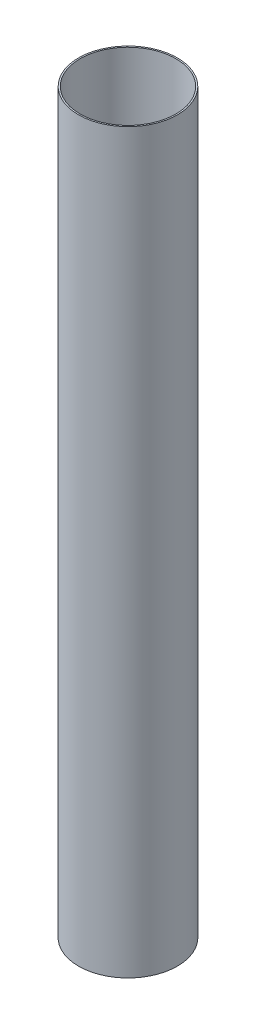
from build123d import *

# Parameters (mm, degrees)
SKETCH1_R           = 67
SKETCH1_R_2         = 65
BOSS_EXTRUDE1_DEPTH = 500


with BuildPart() as part:
    # Sketch1 → Boss-Extrude1 (new body, symmetric)
    with BuildSketch(Plane(origin=(0, 0, 0), x_dir=(1, 0, 0), z_dir=(0, 1, 0))):
        Circle(SKETCH1_R)
        Circle(SKETCH1_R_2, mode=Mode.SUBTRACT)
    extrude(amount=BOSS_EXTRUDE1_DEPTH, both=True)


solid = part.part
